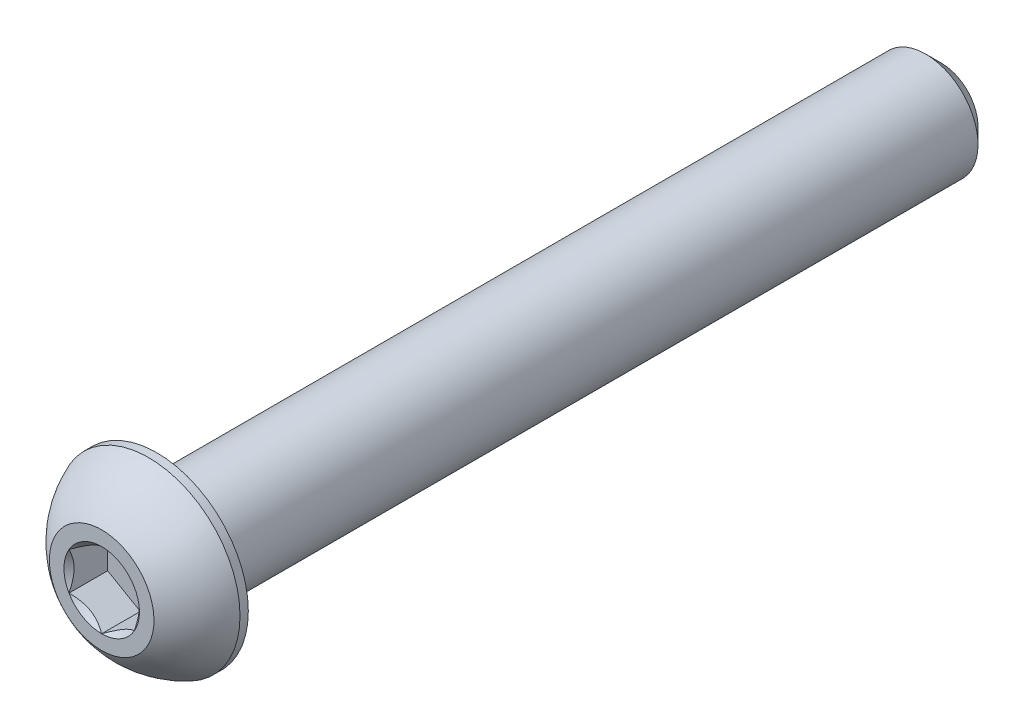
from build123d import *

# Parameters (mm, degrees)
SKETCH1_W          = 47.625
SKETCH1_H          = 3.175
CHAMFER1_SIZE      = 0.9525
CUT_EXTRUDE2_DEPTH = 2.34696


with BuildPart() as part:
    # Sketch1 → Revolve1 (revolve)
    with BuildSketch(Plane(origin=(0, 0, 0), x_dir=(0, 0, -1), z_dir=(1, 0, 0))):
        with Locations((27.1653, 1.5875)):
            Rectangle(SKETCH1_W, SKETCH1_H)
    revolve(axis=Axis((0, 0, -50.9778), (0, 0, 1)))

    # Chamfer1
    chamfer1_edges = [part.edges().sort_by_distance(p)[0] for p in [
        (0, -3.175, -50.9778),
    ]]
    chamfer(chamfer1_edges, length=CHAMFER1_SIZE)

    # Sketch7 → Revolve2 (revolve)
    with BuildSketch(Plane(origin=(0, 0, 0), x_dir=(0, 0, -1), z_dir=(1, 0, 0))):
        with BuildLine():
            Line((2.84988, 5.5499), (3.3528, 5.5499))
            Line((3.3528, 5.5499), (3.3528, 0))
            Line((3.3528, 0), (0, 0))
            Line((0, 0), (0, 3.175))
            ThreePointArc((0, 3.175), (1.235921075, 4.58927271), (2.84988, 5.5499))
        make_face()
    revolve(axis=Axis((0, 0, 0), (0, 0, -1)))

    # Sketch5 → Cut-Extrude2 (cut)
    with BuildSketch(Plane.XY):
        Polygon((1.984375, -1.14567944), (1.984375, 1.14567944), (0, 2.291358881), (-1.984375, 1.14567944), (-1.984375, -1.14567944), (0, -2.291358881), align=None)
    extrude(amount=-CUT_EXTRUDE2_DEPTH, mode=Mode.SUBTRACT)

    # Cut-Extrude3 cone 1 section (through the dimple's axis) → Cut-Extrude3 (revolve, cut)
    with BuildSketch(Plane(origin=(0, 0, 0), x_dir=(0, -1, 0), z_dir=(1, 0, 0))):
        Polygon((0, 0), (2.291358881, 0), (0, 2.291358881), align=None)
    revolve(axis=Axis((0, 0, 0), (0, 0, -1)), mode=Mode.SUBTRACT)


solid = part.part
